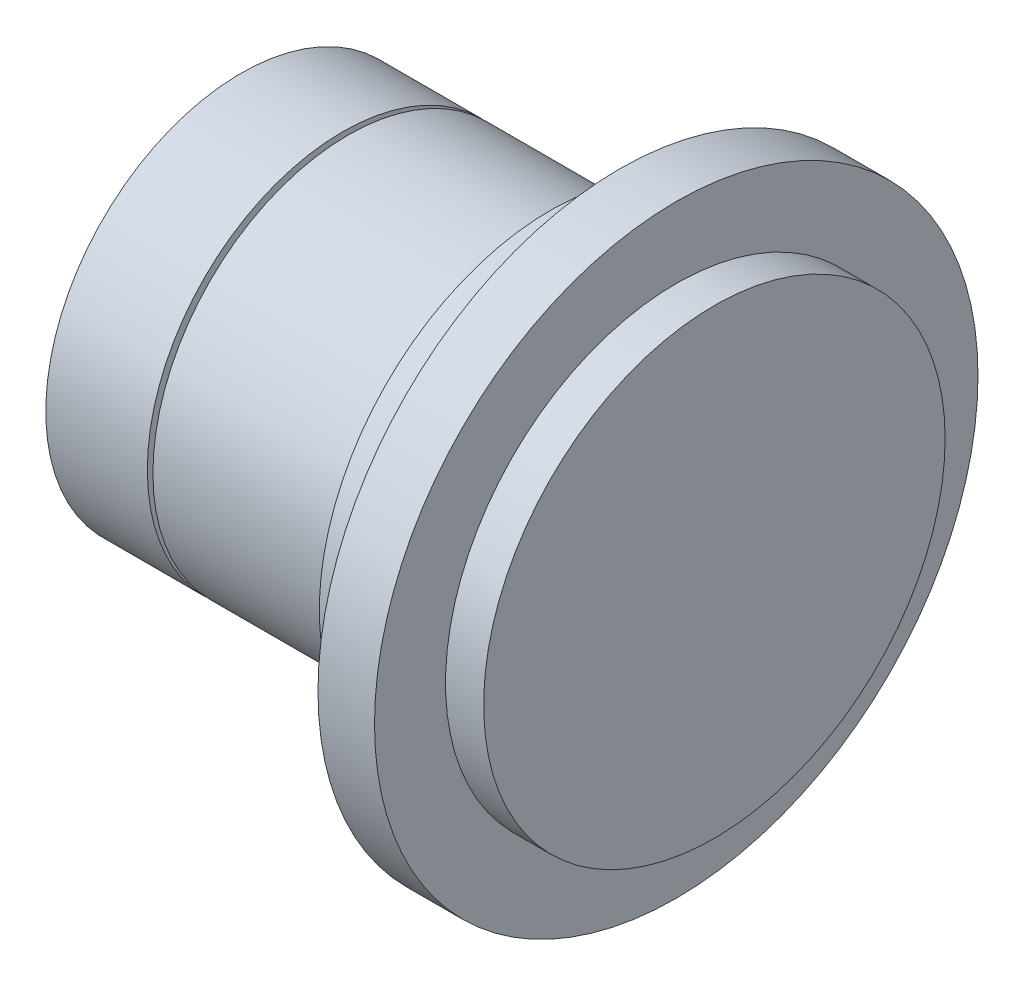
from build123d import *

# Parameters (mm, degrees)
SKICA3_R                 = 38.468571429
SKICA3_R_2               = 6.2
ODEBRAT_VYSUNUT_M1_DEPTH = 1.1


with BuildPart() as part:
    # Skica1 → Rotovat1 (revolve)
    with BuildSketch(Plane.XY):
        Polygon((0, 0), (93.257142857, 0), (93.257142857, 45.462857143), (85.744761905, 45.462857143), (85.744761905, 59.451428571), (74.605714286, 59.451428571), (74.605714286, 45.462857143), (60.876190476, 45.462857143), (60.876190476, 38.468571429), (0, 38.468571429), align=None)
    revolve(axis=Axis((0, 0, 0), (-1, 0, 0)))

    # Skica3 → Odebrat vysunutím1 (cut)
    with BuildSketch(Plane.ZY.offset(-20)):
        Circle(SKICA3_R)
        Circle(SKICA3_R_2, mode=Mode.SUBTRACT)
    extrude(amount=-ODEBRAT_VYSUNUT_M1_DEPTH, mode=Mode.SUBTRACT)


solid = part.part
